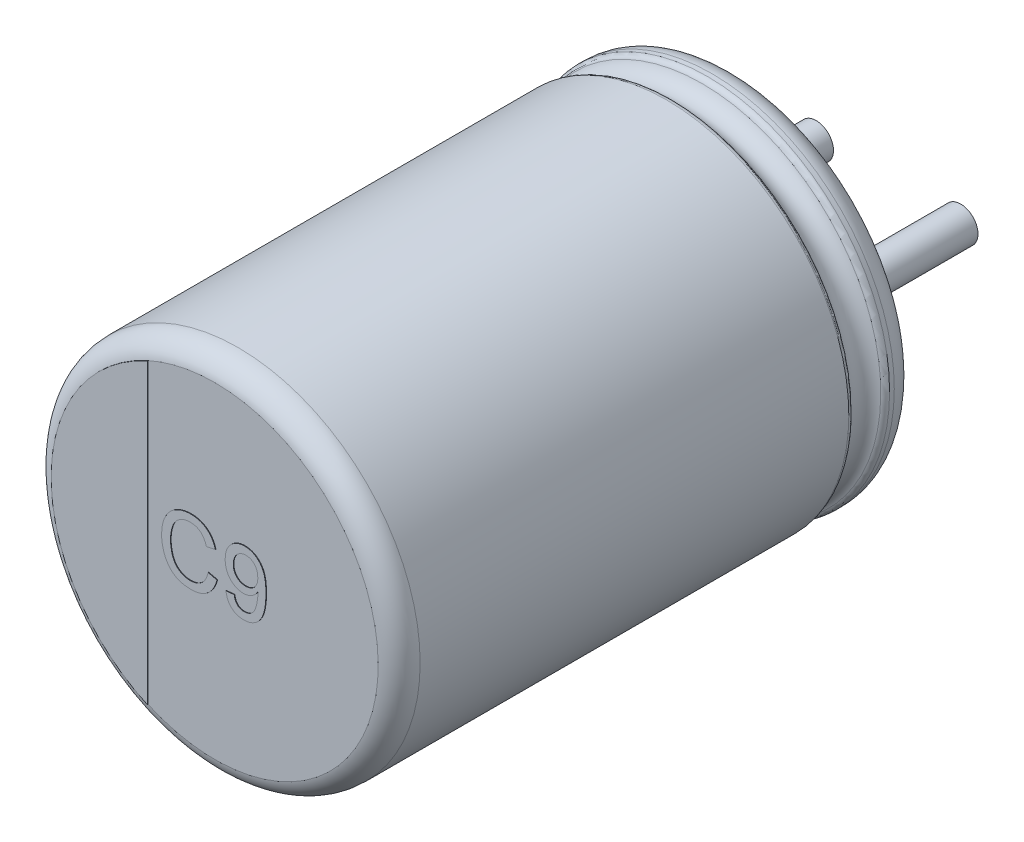
from build123d import *

# Parameters (mm, degrees)
SKETCH_2_R         = 0.3
EXTRUDE_1_DEPTH    = 2.7
EXTRUDE_2_DEPTH    = 0.01
EXTRUDE_1853_DEPTH = 0.01
EXTRUDE_5_DEPTH    = 0.05


with BuildPart() as part:
    # Sketch10 → Повернуть1 (revolve)
    with BuildSketch(Plane(origin=(0, 0, 0), x_dir=(0, 0, -1), z_dir=(1, 0, 0))):
        with BuildLine():
            Line((-9, 0), (-0.05, 0))
            Line((-0.05, 0), (-0.05, 2.553143426))
            ThreePointArc((-0.05, 2.553143426), (-0.052704561, 2.951565585), (-0.398206102, 3.15))
            Line((-0.398206102, 3.15), (-0.479422929, 3.15))
            ThreePointArc((-0.479422929, 3.15), (-0.534479696, 3.133479053), (-0.571344666, 3.089375046))
            ThreePointArc((-0.571344666, 3.089375046), (-0.831990181, 2.917472047), (-1.092635697, 3.089375046))
            ThreePointArc((-1.092635697, 3.089375046), (-1.129500666, 3.133479053), (-1.184557434, 3.15))
            Line((-1.184557434, 3.15), (-8.6, 3.15))
            ThreePointArc((-8.6, 3.15), (-8.85971595, 3.059961924), (-9, 2.82357323))
            Line((-9, 2.82357323), (-9, 0))
        make_face()
    revolve(axis=Axis((0, 0, -18.1630778), (0, 0, 1)))

    # Эскиз2 → Бобышка-Вытянуть1 (add)
    with BuildSketch(Plane(origin=(0, 0, 0.05), x_dir=(-1, 0, 0), z_dir=(0, 0, -1))):
        with Locations(Location((-1.25, 0, 0), (0, 0, 90))):
            Circle(SKETCH_2_R)
        with Locations(Location((1.25, 0, 0), (0, 0, 270))):
            Circle(SKETCH_2_R)
    extrude(amount=EXTRUDE_1_DEPTH)

    # Эскиз4 → Бобышка-Вытянуть2 (add)
    with BuildSketch(Plane.XY.offset(9)):
        with BuildLine():
            Line((-1.160332513, -2.574139515), (-1.160332513, 2.574139515))
            ThreePointArc((-1.160332513, 2.574139515), (-2.82357323, 0), (-1.160332513, -2.574139515))
        make_face()
    extrude(amount=EXTRUDE_2_DEPTH)

    # Эскиз5 → Extrude 1853 (add)
    with BuildSketch(Plane.XY.offset(9)):
        with BuildLine():
            Line((-0.108912855, -0.069918347), (0.04621535, -0.106056167))
            add(Edge.make_bspline(
                [(0.04621535, -0.106056167), (0.042328955, -0.120595903), (0.034726685, -0.149037431), (0.019696074, -0.189740405), (0.002826055, -0.22793841), (-0.016292712, -0.263530826), (-0.037869483, -0.296313018), (-0.061332559, -0.326706301), (-0.08761128, -0.354073299), (-0.115741448, -0.379045627), (-0.145942088, -0.401071154), (-0.177849082, -0.420090601), (-0.2113082, -0.436272289), (-0.246454673, -0.449579116), (-0.283311287, -0.459593644), (-0.321688266, -0.466892819), (-0.361697515, -0.471388685), (-0.388969191, -0.471980579), (-0.402863176, -0.472282129)],
                knots=[0, 0, 0, 0, 1.145254194, 2.240259345, 3.299159039, 4.322497661, 5.312016644, 6.284080175, 7.241264552, 8.196044782, 9.144516039, 10.082428046, 11.020306713, 11.970622414, 12.939253955, 13.924100776, 14.94240044, 16, 16, 16, 16], degree=3))
            add(Edge.make_bspline(
                [(-0.402863176, -0.472282129), (-0.417118674, -0.472075022), (-0.445008416, -0.471669834), (-0.48586528, -0.468374144), (-0.524724169, -0.462658281), (-0.561512517, -0.454716909), (-0.596354147, -0.444897895), (-0.629104581, -0.432544706), (-0.659706455, -0.417746474), (-0.68841503, -0.40091706), (-0.715108371, -0.381798088), (-0.740393493, -0.360905526), (-0.763656558, -0.337664227), (-0.785479231, -0.312622937), (-0.805386205, -0.285451329), (-0.824109863, -0.25651854), (-0.840736314, -0.225314775), (-0.855881721, -0.192418552), (-0.869175168, -0.158148367), (-0.880935219, -0.12318115), (-0.890549703, -0.087447226), (-0.898827154, -0.051247288), (-0.904840321, -0.01427674), (-0.90961459, 0.023187027), (-0.912239578, 0.061373697), (-0.912584999, 0.087042498), (-0.912759009, 0.09997348)],
                knots=[0, 0, 0, 0, 1.180702053, 2.309949215, 3.392367133, 4.431746864, 5.425408375, 6.388154007, 7.326956194, 8.237882283, 9.141054626, 10.043899035, 10.951650021, 11.86168169, 12.792564695, 13.739356664, 14.713891418, 15.718426911, 16.737522708, 17.757217648, 18.772674716, 19.801476837, 20.831699174, 21.873853055, 22.928926693, 24, 24, 24, 24], degree=3))
            add(Edge.make_bspline(
                [(-0.912759009, 0.09997348), (-0.912510138, 0.113932996), (-0.912018432, 0.141513475), (-0.909242757, 0.182209272), (-0.904144849, 0.221485694), (-0.897065337, 0.259368577), (-0.888106922, 0.295888601), (-0.877048763, 0.331063557), (-0.864030746, 0.364848441), (-0.849092557, 0.397280506), (-0.83213495, 0.427997725), (-0.81366404, 0.457043765), (-0.793239225, 0.483941703), (-0.771466071, 0.509205432), (-0.747800778, 0.532414283), (-0.72231561, 0.553620827), (-0.695230442, 0.573018497), (-0.666549228, 0.590427213), (-0.636646863, 0.605702449), (-0.605967495, 0.619308236), (-0.574389099, 0.630460027), (-0.542162036, 0.639732294), (-0.509216926, 0.647113879), (-0.475476789, 0.652049968), (-0.4409728, 0.655266706), (-0.417707516, 0.655702651), (-0.405948112, 0.655922999)],
                knots=[0, 0, 0, 0, 1.185634383, 2.342514083, 3.462112933, 4.547331452, 5.613960142, 6.653690668, 7.676612054, 8.686959706, 9.683658101, 10.654407272, 11.607580201, 12.5494388, 13.484601218, 14.419076806, 15.362504069, 16.311442244, 17.265594461, 18.212500624, 19.159571152, 20.107257795, 21.059246075, 22.024387127, 23.001429356, 24, 24, 24, 24], degree=3))
            add(Edge.make_bspline(
                [(-0.405948112, 0.655922999), (-0.392790923, 0.655674993), (-0.366929166, 0.655187511), (-0.328981645, 0.651177881), (-0.292637827, 0.64446219), (-0.25774023, 0.635651838), (-0.224651675, 0.623588633), (-0.19301293, 0.609246868), (-0.163138738, 0.592016975), (-0.134796652, 0.572372462), (-0.108448038, 0.5502771), (-0.083724175, 0.526258741), (-0.061633171, 0.499717103), (-0.04130009, 0.471294538), (-0.023364678, 0.440596924), (-0.007167108, 0.407891911), (0.006762331, 0.372936375), (0.014215274, 0.348588877), (0.018010222, 0.336191429)],
                knots=[0, 0, 0, 0, 1.098391872, 2.158997981, 3.181470371, 4.182549255, 5.160268219, 6.118029851, 7.079534476, 8.035645336, 8.993622929, 9.94770573, 10.909620999, 11.872786677, 12.862530088, 13.874594564, 14.917769567, 16, 16, 16, 16], degree=3))
            Line((0.018010222, 0.336191429), (-0.137117984, 0.302918192))
            add(Edge.make_bspline(
                [(-0.137117984, 0.302918192), (-0.140164459, 0.312432596), (-0.146127355, 0.331055231), (-0.15671506, 0.357595794), (-0.168149428, 0.382234108), (-0.180702836, 0.404802692), (-0.194402488, 0.425306953), (-0.20893292, 0.443996089), (-0.224642265, 0.460521265), (-0.241210981, 0.47526351), (-0.259066923, 0.487822492), (-0.277791469, 0.498951816), (-0.297779426, 0.508159635), (-0.318743252, 0.515947548), (-0.340878894, 0.521874989), (-0.364096214, 0.526045177), (-0.388415609, 0.528458678), (-0.404987911, 0.528817113), (-0.413440099, 0.528999922)],
                knots=[0, 0, 0, 0, 1.235697765, 2.418642872, 3.532555292, 4.594392283, 5.610119701, 6.580908344, 7.519430642, 8.427315627, 9.319973334, 10.216139639, 11.118687699, 12.038725643, 12.980015607, 13.949697744, 14.954307006, 16, 16, 16, 16], degree=3))
            add(Edge.make_bspline(
                [(-0.413440099, 0.528999922), (-0.423143984, 0.528859129), (-0.442228662, 0.528582229), (-0.47026635, 0.525551592), (-0.497192283, 0.52108776), (-0.522805782, 0.51439386), (-0.547247006, 0.506048307), (-0.570370917, 0.495656617), (-0.592374217, 0.483476338), (-0.613011338, 0.469434324), (-0.632108844, 0.453648399), (-0.650184985, 0.436960206), (-0.666371907, 0.418591447), (-0.681286864, 0.399147811), (-0.694495535, 0.378285716), (-0.706385552, 0.356289328), (-0.716881124, 0.332978371), (-0.72832201, 0.300169965), (-0.739987527, 0.257913496), (-0.750107378, 0.206205274), (-0.756553484, 0.153682392), (-0.757270938, 0.118354545), (-0.757630804, 0.100634538)],
                knots=[0, 0, 0, 0, 0.935256702, 1.839373932, 2.716087708, 3.564631604, 4.388828665, 5.203538865, 6.005592122, 6.810952829, 7.606223804, 8.392839071, 9.180346482, 9.963639178, 10.753404291, 11.558266631, 12.372976832, 13.215232055, 14.905983541, 16.594894834, 18.292041732, 20, 20, 20, 20], degree=3))
            add(Edge.make_bspline(
                [(-0.757630804, 0.100634538), (-0.757224926, 0.078354594), (-0.756437487, 0.035129485), (-0.748667393, -0.027510838), (-0.73682082, -0.085937398), (-0.722523713, -0.131521756), (-0.708182278, -0.165145637), (-0.696583647, -0.188692925), (-0.683344271, -0.210482444), (-0.668793463, -0.230637938), (-0.652743794, -0.249100614), (-0.635418867, -0.265968548), (-0.616814812, -0.281404048), (-0.59671119, -0.29468455), (-0.575881813, -0.306476479), (-0.554589531, -0.316962087), (-0.53282094, -0.32583035), (-0.51048821, -0.332719396), (-0.487904955, -0.338672491), (-0.464822442, -0.342561331), (-0.441247254, -0.34475607), (-0.425417098, -0.345156447), (-0.417406445, -0.345359052)],
                knots=[0, 0, 0, 0, 2.10686522, 4.087509323, 5.961373225, 7.741398778, 8.594514555, 9.418024779, 10.222433421, 11.003575649, 11.767087398, 12.533660211, 13.289033706, 14.050297079, 14.809623433, 15.552362432, 16.294320901, 17.0305302, 17.761969017, 18.502233515, 19.242073914, 20, 20, 20, 20], degree=3))
            add(Edge.make_bspline(
                [(-0.417406445, -0.345359052), (-0.407846827, -0.345158567), (-0.388963202, -0.344762537), (-0.361277409, -0.34129607), (-0.334588687, -0.336187777), (-0.309220365, -0.328305166), (-0.284831211, -0.318653832), (-0.261621051, -0.306752049), (-0.239662879, -0.292437677), (-0.218698419, -0.276185053), (-0.199114272, -0.257692345), (-0.181166455, -0.237108537), (-0.165065235, -0.214339793), (-0.150135352, -0.189751516), (-0.137591507, -0.162609165), (-0.125972944, -0.133721734), (-0.116291518, -0.102614431), (-0.111407741, -0.080973603), (-0.108912855, -0.069918347)],
                knots=[0, 0, 0, 0, 1.013374089, 2.001772144, 2.95501459, 3.891367103, 4.814208647, 5.733921849, 6.652182523, 7.590185968, 8.54346024, 9.504121027, 10.481158517, 11.497760682, 12.549996529, 13.647863555, 14.798406869, 16, 16, 16, 16], degree=3))
        make_face()
        with BuildLine():
            Line((0.201343555, -0.190230847), (0.342369196, -0.176128283))
            add(Edge.make_bspline(
                [(0.342369196, -0.176128283), (0.343644152, -0.183353882), (0.34610875, -0.197321577), (0.351670571, -0.217227936), (0.357311621, -0.235788689), (0.364593458, -0.252590345), (0.37217696, -0.268089284), (0.380765067, -0.282130196), (0.390510792, -0.294431072), (0.404273035, -0.308845506), (0.423799655, -0.323887213), (0.450866196, -0.336071582), (0.480641933, -0.344263993), (0.501625629, -0.344985688), (0.512481375, -0.345359052)],
                knots=[0, 0, 0, 0, 0.994516507, 1.922484754, 2.80151264, 3.623050913, 4.402748861, 5.140924173, 5.850441436, 6.526872911, 7.841975818, 9.161260782, 10.53140107, 12, 12, 12, 12], degree=3))
            add(Edge.make_bspline(
                [(0.512481375, -0.345359052), (0.521980259, -0.345016989), (0.540675535, -0.344343755), (0.567933866, -0.339124792), (0.593856115, -0.330764123), (0.617991048, -0.318768314), (0.640250826, -0.30416975), (0.659693992, -0.286823714), (0.676580172, -0.26747728), (0.690448971, -0.245186476), (0.702286365, -0.219726636), (0.713471129, -0.190773964), (0.72405173, -0.157829656), (0.733455145, -0.121313905), (0.741875444, -0.082559835), (0.747784728, -0.042445572), (0.75142048, -0.001750999), (0.751809423, 0.025633649), (0.752004613, 0.039376525)],
                knots=[0, 0, 0, 0, 0.897794352, 1.766998465, 2.614902619, 3.466100941, 4.308008728, 5.124841802, 5.922729683, 6.728261092, 7.598214292, 8.574707161, 9.662086263, 10.868425066, 12.139522319, 13.41071447, 14.70057738, 16, 16, 16, 16], degree=3))
            add(Edge.make_bspline(
                [(0.752004613, 0.039376525), (0.75193786, 0.043122679), (0.751778157, 0.052085132), (0.751503443, 0.061044837), (0.751343555, 0.066259538)],
                knots=[0, 0, 0, 0, 0.835966126, 2, 2, 2, 2], degree=3))
            add(Edge.make_bspline(
                [(0.751343555, 0.066259538), (0.744544932, 0.055935336), (0.730958642, 0.035303567), (0.705929341, 0.007613237), (0.67729538, -0.016948462), (0.645491403, -0.038190806), (0.611302726, -0.055623975), (0.575324124, -0.068291622), (0.537865747, -0.076113728), (0.512372175, -0.076974871), (0.499480574, -0.077410334)],
                knots=[0, 0, 0, 0, 0.978840568, 1.956103883, 2.947027447, 3.962820877, 4.980997961, 5.980964245, 6.979013046, 8, 8, 8, 8], degree=3))
            add(Edge.make_bspline(
                [(0.499480574, -0.077410334), (0.48873753, -0.077131994), (0.467589641, -0.076584075), (0.436611705, -0.071714348), (0.406817002, -0.064411485), (0.378487871, -0.053354595), (0.35118355, -0.039680069), (0.325190734, -0.022895636), (0.300469372, -0.003024142), (0.277338903, 0.019686979), (0.256230315, 0.045001495), (0.237614976, 0.072302697), (0.222156824, 0.101724079), (0.209295107, 0.132898419), (0.199370937, 0.166126925), (0.192474939, 0.20133174), (0.187837049, 0.238378476), (0.187442312, 0.263754228), (0.187240991, 0.276696236)],
                knots=[0, 0, 0, 0, 0.975490236, 1.920271282, 2.842894855, 3.757591483, 4.67685385, 5.613562631, 6.563069669, 7.554119451, 8.55387214, 9.553424333, 10.550567425, 11.568071726, 12.613215376, 13.695622473, 14.824733476, 16, 16, 16, 16], degree=3))
            add(Edge.make_bspline(
                [(0.187240991, 0.276696236), (0.187542518, 0.290076649), (0.188132358, 0.316251055), (0.192587886, 0.354521288), (0.199959155, 0.390777572), (0.210709133, 0.424950702), (0.224003263, 0.45726025), (0.240766644, 0.487473272), (0.260353787, 0.515719008), (0.282881726, 0.541725147), (0.307639726, 0.565059852), (0.333925555, 0.585886483), (0.362081737, 0.603005874), (0.391568402, 0.617279175), (0.422608697, 0.628309798), (0.45514957, 0.63628262), (0.489281068, 0.640960823), (0.512540378, 0.641530463), (0.524380414, 0.641820435)],
                knots=[0, 0, 0, 0, 1.151671969, 2.252870106, 3.311924673, 4.331900944, 5.332425074, 6.314476151, 7.300265758, 8.286521684, 9.270545387, 10.225535917, 11.167946231, 12.101233205, 13.04124339, 13.998220545, 14.981004193, 16, 16, 16, 16], degree=3))
            add(Edge.make_bspline(
                [(0.524380414, 0.641820435), (0.532979691, 0.641646518), (0.550072179, 0.641300828), (0.57550935, 0.638661599), (0.600344172, 0.633903957), (0.624738565, 0.627898476), (0.648281064, 0.619562415), (0.671425488, 0.609922615), (0.69389268, 0.59813241), (0.715813555, 0.584725469), (0.737050433, 0.569937461), (0.756589584, 0.552947641), (0.775211978, 0.534917457), (0.792538674, 0.515281039), (0.808021629, 0.493735333), (0.822711977, 0.471042085), (0.835901569, 0.446706121), (0.847929562, 0.420694481), (0.858634941, 0.392471726), (0.86756591, 0.36141416), (0.875221743, 0.327414215), (0.881595979, 0.290426822), (0.886322578, 0.250478351), (0.88980108, 0.207628173), (0.892078305, 0.161843695), (0.892270327, 0.130311524), (0.892369196, 0.114076044)],
                knots=[0, 0, 0, 0, 0.850689348, 1.69088598, 2.526071361, 3.350886897, 4.173587108, 4.994166539, 5.82944675, 6.680632524, 7.535501428, 8.385942454, 9.238956306, 10.098905971, 10.972410977, 11.861345628, 12.77184846, 13.708225841, 14.694799433, 15.754852217, 16.902446579, 18.141290626, 19.466225842, 20.880733292, 22.39393263, 24, 24, 24, 24], degree=3))
            add(Edge.make_bspline(
                [(0.892369196, 0.114076044), (0.892269665, 0.097106171), (0.892075683, 0.064032572), (0.88978058, 0.01575351), (0.886303828, -0.029884616), (0.881573888, -0.072911776), (0.875155216, -0.113262303), (0.867526114, -0.150929141), (0.858528889, -0.185981831), (0.847955838, -0.218423449), (0.835936323, -0.248626816), (0.822766485, -0.276963843), (0.808016995, -0.303392623), (0.79185358, -0.327963842), (0.774483788, -0.350720447), (0.755636417, -0.371601475), (0.735305347, -0.390543808), (0.713749734, -0.407760621), (0.691001928, -0.422932958), (0.667371604, -0.436320658), (0.642592081, -0.447287527), (0.6169181, -0.456284353), (0.590395282, -0.463712693), (0.562807595, -0.468717921), (0.534282495, -0.471552712), (0.51498489, -0.472036876), (0.505209741, -0.472282129)],
                knots=[0, 0, 0, 0, 1.538356107, 2.998194159, 4.380716326, 5.687456969, 6.921258146, 8.08355215, 9.170518603, 10.200253214, 11.174652363, 12.115998813, 13.031191965, 13.915860606, 14.780247615, 15.624154577, 16.462764255, 17.29681422, 18.1223677, 18.939254916, 19.756006416, 20.575278551, 21.404021733, 22.250368457, 23.113728878, 24, 24, 24, 24], degree=3))
            add(Edge.make_bspline(
                [(0.505209741, -0.472282129), (0.494841484, -0.472102861), (0.474555946, -0.471752122), (0.444941149, -0.468064081), (0.416729123, -0.462457055), (0.390001975, -0.454179758), (0.364559544, -0.443990628), (0.340836084, -0.430969498), (0.318409997, -0.41594701), (0.297557952, -0.398620223), (0.278524099, -0.379052765), (0.2613021, -0.357726883), (0.24620348, -0.334366372), (0.233307257, -0.309108956), (0.221884195, -0.282167129), (0.213028215, -0.253179617), (0.205833583, -0.222413771), (0.2028644, -0.201131722), (0.201343555, -0.190230847)],
                knots=[0, 0, 0, 0, 1.08199657, 2.11693069, 3.111083497, 4.081436044, 5.034173265, 5.967546613, 6.901297947, 7.84883568, 8.792454994, 9.747011506, 10.706361727, 11.690764787, 12.70483191, 13.757514363, 14.851376857, 16, 16, 16, 16], degree=3))
        make_face()
        with BuildLine():
            add(Edge.make_bspline(
                [(0.751343555, 0.279781172), (0.751184944, 0.288602273), (0.750876219, 0.305771978), (0.748171411, 0.330822365), (0.743819393, 0.354412389), (0.737711015, 0.376677695), (0.729415655, 0.397382263), (0.719806047, 0.41700949), (0.708054462, 0.435015366), (0.694794863, 0.451642355), (0.680189147, 0.466514812), (0.664283656, 0.479482265), (0.647376608, 0.490598311), (0.629062398, 0.499338514), (0.609943075, 0.506540409), (0.589559366, 0.511247288), (0.568191749, 0.51454455), (0.553480391, 0.51477817), (0.545974965, 0.514897358)],
                knots=[0, 0, 0, 0, 1.20361398, 2.342757417, 3.433960756, 4.474970456, 5.487648377, 6.473933575, 7.452701285, 8.415527761, 9.372491588, 10.291530068, 11.211879743, 12.12647906, 13.055739058, 13.994253148, 14.97671008, 16, 16, 16, 16], degree=3))
            add(Edge.make_bspline(
                [(0.545974965, 0.514897358), (0.538254944, 0.514663421), (0.523046484, 0.514202563), (0.50075546, 0.511234619), (0.47961517, 0.50555192), (0.459482893, 0.498013949), (0.440135032, 0.488689611), (0.422274957, 0.476471879), (0.405154626, 0.46262616), (0.389460709, 0.446563282), (0.375124834, 0.428952072), (0.362493347, 0.409957831), (0.351856035, 0.389571252), (0.343352831, 0.367877333), (0.336403748, 0.34506516), (0.331630222, 0.320930756), (0.328693004, 0.295499815), (0.328410874, 0.278100075), (0.328266632, 0.269204249)],
                knots=[0, 0, 0, 0, 1.007165334, 1.984118292, 2.925321257, 3.856078893, 4.785899085, 5.718627206, 6.671847665, 7.654235469, 8.641842333, 9.630378272, 10.624608936, 11.635186472, 12.665777387, 13.731187195, 14.840042241, 16, 16, 16, 16], degree=3))
            add(Edge.make_bspline(
                [(0.328266632, 0.269204249), (0.32839985, 0.261259972), (0.328661041, 0.245684334), (0.331771526, 0.222953108), (0.335920451, 0.201258229), (0.342534623, 0.180821147), (0.350502779, 0.161345156), (0.36085893, 0.14327755), (0.372518971, 0.126078072), (0.386180966, 0.110322908), (0.401284331, 0.096030212), (0.417780271, 0.083572589), (0.435460425, 0.072908648), (0.45448905, 0.064325686), (0.474752033, 0.057715544), (0.496204144, 0.052849145), (0.518938631, 0.049950598), (0.534508162, 0.049660636), (0.542449324, 0.049512743)],
                knots=[0, 0, 0, 0, 1.102204012, 2.160993585, 3.181057555, 4.164839289, 5.138418409, 6.097303793, 7.050641095, 8.019669129, 8.986440483, 9.932879371, 10.884360123, 11.847412593, 12.824617322, 13.839006415, 14.897795988, 16, 16, 16, 16], degree=3))
            add(Edge.make_bspline(
                [(0.542449324, 0.049512743), (0.54987688, 0.049662082), (0.564495971, 0.049956013), (0.585911403, 0.052866917), (0.606260089, 0.057742341), (0.625633393, 0.064370684), (0.643999913, 0.072950678), (0.661236146, 0.083699364), (0.67767528, 0.096014629), (0.692835421, 0.110404415), (0.706691236, 0.126336723), (0.718673939, 0.143968948), (0.728906525, 0.162980886), (0.736960611, 0.183597891), (0.743411552, 0.20556613), (0.747953443, 0.229024689), (0.750927848, 0.25392349), (0.75120289, 0.271031586), (0.751343555, 0.279781172)],
                knots=[0, 0, 0, 0, 1.017004716, 2.00169281, 2.953445817, 3.879374072, 4.80207141, 5.723561102, 6.657273834, 7.611045633, 8.581233951, 9.544037932, 10.525327521, 11.53237926, 12.57032081, 13.657564536, 14.802009319, 16, 16, 16, 16], degree=3))
        make_face(mode=Mode.SUBTRACT)
    extrude(amount=EXTRUDE_1853_DEPTH)

    # Эскиз6 → Бобышка-Вытянуть5 (add)
    with BuildSketch(Plane(origin=(0, 0, 0.05), x_dir=(-1, 0, 0), z_dir=(0, 0, -1))):
        with BuildLine():
            Line((-1.25, 0.4), (-1.624807681, 0.4))
            ThreePointArc((-1.624807681, 0.4), (-1.831827349, 0.509847022), (-1.856923064, 0.742857143))
            ThreePointArc((-1.856923064, 0.742857143), (0, 2), (1.856923064, 0.742857143))
            ThreePointArc((1.856923064, 0.742857143), (1.831827349, 0.509847022), (1.624807681, 0.4))
            Line((1.624807681, 0.4), (1.25, 0.4))
            ThreePointArc((1.25, 0.4), (0.85, 0), (1.25, -0.4))
            Line((1.25, -0.4), (1.624807681, -0.4))
            ThreePointArc((1.624807681, -0.4), (1.831827349, -0.509847022), (1.856923064, -0.742857143))
            ThreePointArc((1.856923064, -0.742857143), (0, -2), (-1.856923064, -0.742857143))
            ThreePointArc((-1.856923064, -0.742857143), (-1.831827349, -0.509847022), (-1.624807681, -0.4))
            Line((-1.624807681, -0.4), (-1.25, -0.4))
            ThreePointArc((-1.25, -0.4), (-0.85, 0), (-1.25, 0.4))
        make_face()
    extrude(amount=EXTRUDE_5_DEPTH)


solid = part.part
